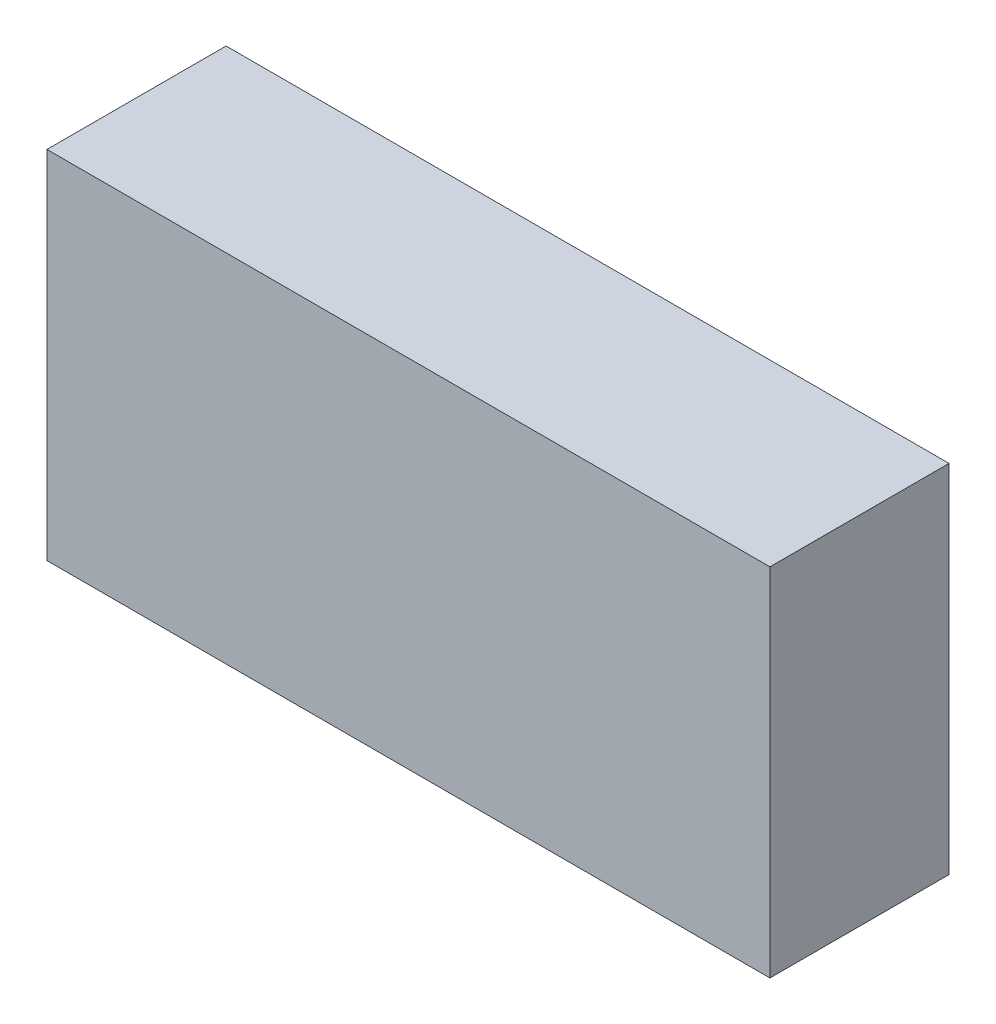
from build123d import *

# Parameters (mm, degrees)
SKETCH1_W           = 85.09
SKETCH1_H           = 41.91
BOSS_EXTRUDE1_DEPTH = 21.082


with BuildPart() as part:
    # Sketch1 → Boss-Extrude1 (new body)
    with BuildSketch(Plane.XY):
        with Locations((42.545, 20.955)):
            Rectangle(SKETCH1_W, SKETCH1_H)
    extrude(amount=BOSS_EXTRUDE1_DEPTH)


solid = part.part
